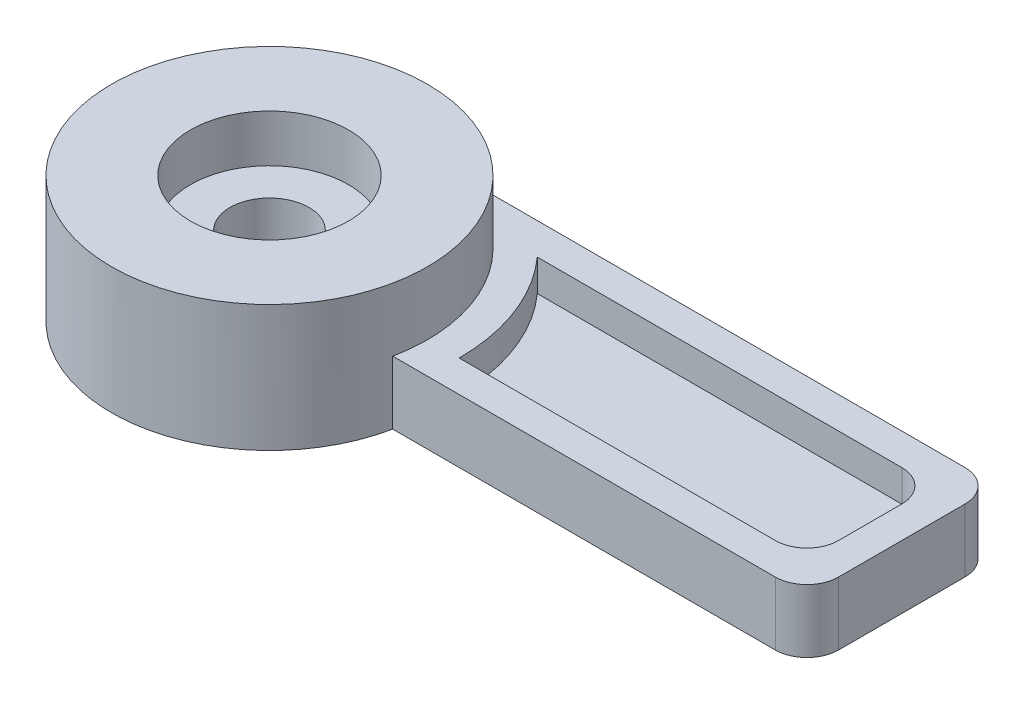
from build123d import *

# Parameters (mm, degrees)
EXTRUDE_1_DEPTH                = 20
EXTRUDE_2_DEPTH                = 40
EXTRUDE_3_DEPTH                = 10
FILLET_1_R                     = 10
HOLE_WIZARD_M1_6_1_D           = 25
HOLE_WIZARD_M1_6_1_CBORE_D     = 50
HOLE_WIZARD_M1_6_1_CBORE_DEPTH = 15


with BuildPart() as part:
    # 스케치2 → 보스-돌출1 (new body)
    with BuildSketch(Plane(origin=(0, 0, 0), x_dir=(1, 0, 0), z_dir=(0, 1, 0))):
        with BuildLine():
            Line((180, 50), (0, 50))
            ThreePointArc((0, 50), (35.355339059, 35.355339059), (50, 0))
            ThreePointArc((50, 0), (49.74680765, -5.0254481), (48.989794856, -10))
            Line((48.989794856, -10), (180, -10))
            Line((180, -10), (180, 50))
        make_face()
        with BuildLine():
            ThreePointArc((60, 0), (56.050341538, 21.409325386), (44.72135955, 40))
            Line((44.72135955, 40), (170, 40))
            Line((170, 40), (170, 0))
            Line((170, 0), (60, 0))
        make_face(mode=Mode.SUBTRACT)
    extrude(amount=EXTRUDE_1_DEPTH)

    # 스케치2<4> → 보스-돌출2 (add)
    with BuildSketch(Plane(origin=(0, 0, 0), x_dir=(1, 0, 0), z_dir=(0, 1, 0))):
        with BuildLine():
            ThreePointArc((50, 0), (35.355339059, 35.355339059), (0, 50))
            ThreePointArc((0, 50), (-38.729833462, -31.622776602), (48.989794856, -10))
            ThreePointArc((48.989794856, -10), (49.74680765, -5.0254481), (50, 0))
        make_face()
    extrude(amount=EXTRUDE_2_DEPTH)

    # 스케치2<5> → 보스-돌출3 (add)
    with BuildSketch(Plane(origin=(0, 0, 0), x_dir=(1, 0, 0), z_dir=(0, 1, 0))):
        with BuildLine():
            Line((44.72135955, 40), (170, 40))
            Line((170, 40), (170, 0))
            Line((170, 0), (60, 0))
            ThreePointArc((60, 0), (56.050341538, 21.409325386), (44.72135955, 40))
        make_face()
    extrude(amount=EXTRUDE_3_DEPTH)

    # 필렛1
    fillet_1_edges = [part.edges().sort_by_distance(p)[0] for p in [
        (180, 10, -50),
        (170, 15, -40),
        (170, 15, 0),
        (180, 10, 10),
    ]]
    fillet(fillet_1_edges, radius=FILLET_1_R)

    # M1.6 남비 머리 나사용 카운터보어1 (through all)
    with Locations(Plane(origin=(0, 40, 0), x_dir=(1, 0, 0), z_dir=(0, 1, 0))):
        with Locations((0, 0)):
            CounterBoreHole(HOLE_WIZARD_M1_6_1_D / 2, HOLE_WIZARD_M1_6_1_CBORE_D / 2, HOLE_WIZARD_M1_6_1_CBORE_DEPTH)


solid = part.part
